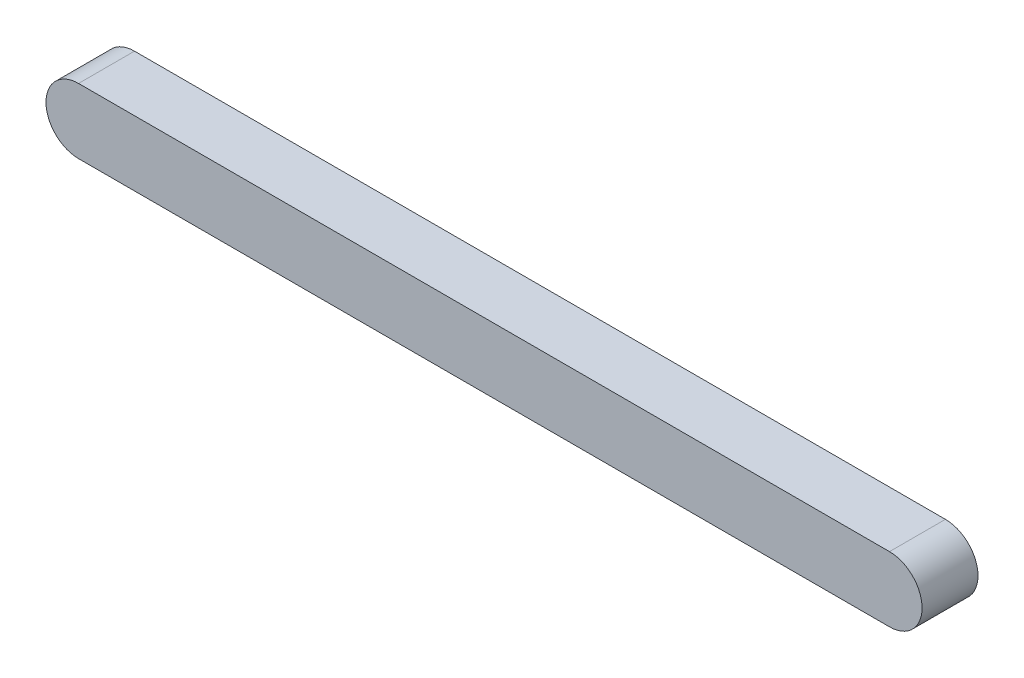
from build123d import *

# Parameters (mm, degrees)
EXTRUDE_1_DEPTH = 10


with BuildPart() as part:
    # 草图1 → 凸台-拉伸1 (new body)
    with BuildSketch(Plane.XY):
        with BuildLine():
            Line((-145, 5.825312786), (0, 5.825312786))
            ThreePointArc((0, 5.825312786), (5.825312786, 0), (0, -5.825312786))
            Line((0, -5.825312786), (-145, -5.825312786))
            ThreePointArc((-145, -5.825312786), (-150.825312786, 0), (-145, 5.825312786))
        make_face()
    extrude(amount=EXTRUDE_1_DEPTH)


solid = part.part
